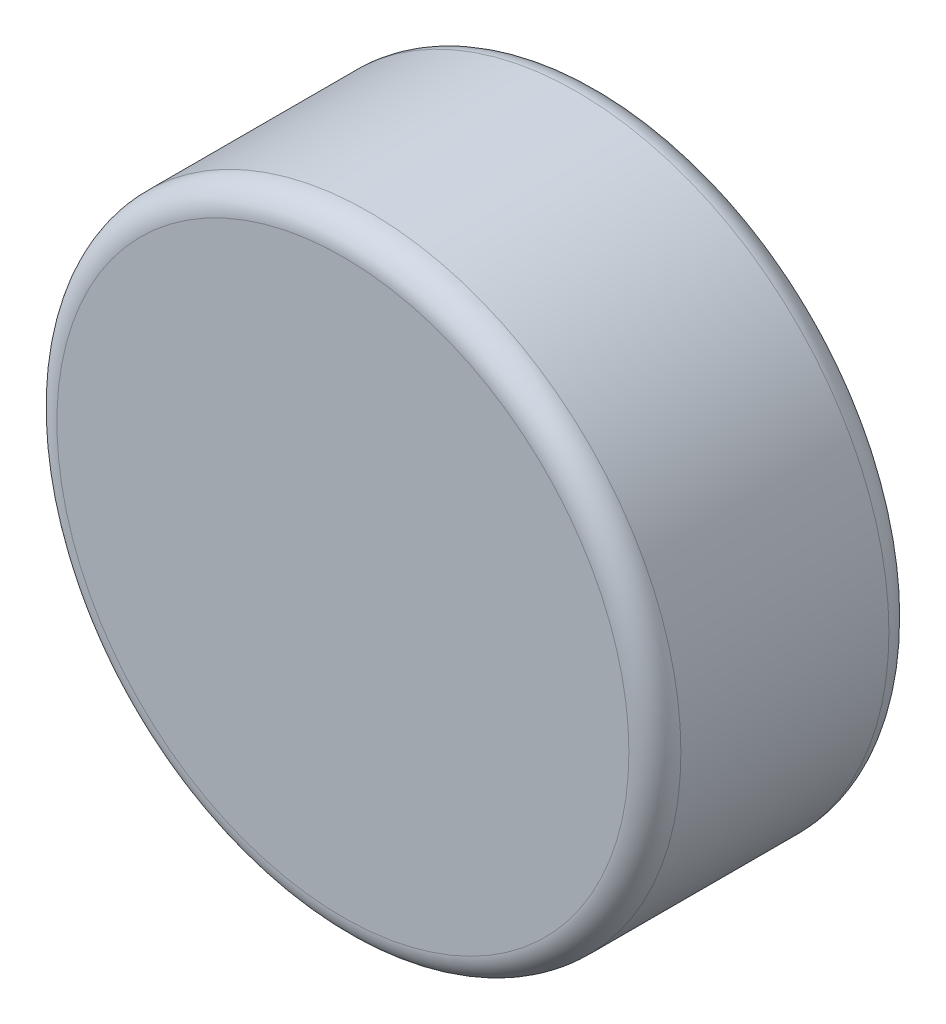
from build123d import *

# Parameters (mm, degrees)
SKETCH1_R           = 3
BOSS_EXTRUDE1_DEPTH = 2.5
FILLET1_R           = 0.25


with BuildPart() as part:
    # Sketch1 → Boss-Extrude1 (new body)
    with BuildSketch(Plane.XY):
        Circle(SKETCH1_R)
    extrude(amount=BOSS_EXTRUDE1_DEPTH)

    # Fillet1
    fillet1_edges = [part.edges().sort_by_distance(p)[0] for p in [
        (-3, 0, 0),
        (-3, 0, 2.5),
    ]]
    fillet(fillet1_edges, radius=FILLET1_R)


solid = part.part
